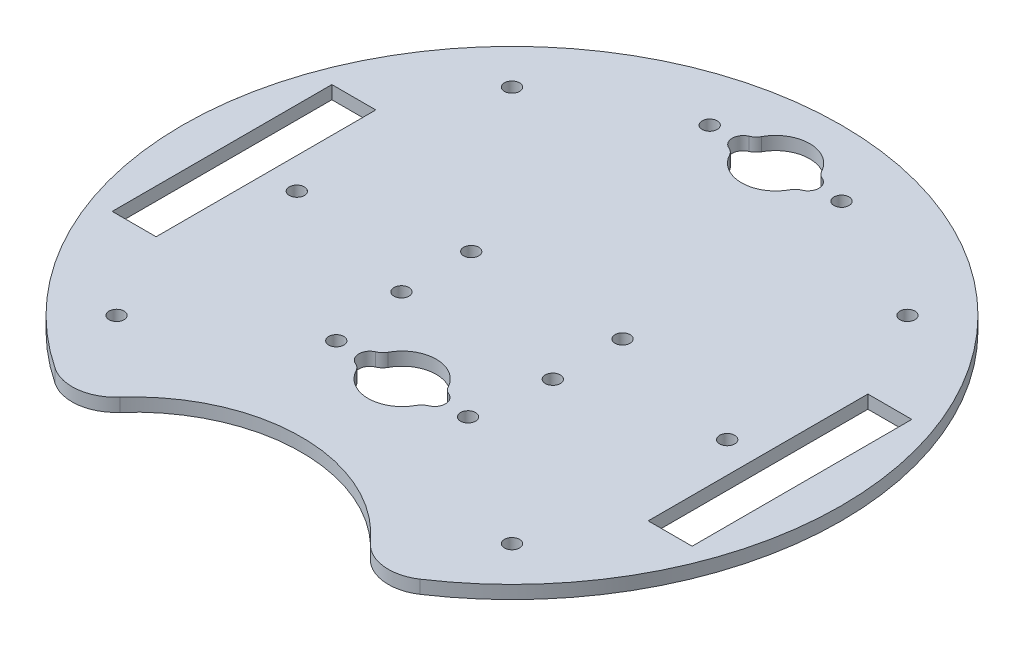
from build123d import *

# Parameters (mm, degrees)
SKETCH1_R           = 75
BOSS_EXTRUDE1_DEPTH = 3
SKETCH2_W           = 10
SKETCH2_H           = 50
CUT_EXTRUDE1_DEPTH  = 6.35
CUT_EXTRUDE2_DEPTH  = 10
CUT_EXTRUDE3_START  = -10
CUT_EXTRUDE3_DEPTH  = 10
FILLET2_R           = 10
SKETCH7_R           = 1.7145
CUT_EXTRUDE5_DEPTH  = 3
SKETCH6_R           = 1.7145
CUT_EXTRUDE6_DEPTH  = 3
FILLET4_R           = 3
SKETCH8_R           = 1.7145
CUT_EXTRUDE7_DEPTH  = 107.108435247


with BuildPart() as part:
    # Sketch1 → Boss-Extrude1 (new body)
    with BuildSketch(Plane(origin=(0, 0, 0), x_dir=(1, 0, 0), z_dir=(0, 1, 0))):
        Circle(SKETCH1_R)
    extrude(amount=BOSS_EXTRUDE1_DEPTH)

    # Sketch2 → Cut-Extrude1 (cut)
    with BuildSketch(Plane(origin=(0, 3, 0), x_dir=(1, 0, 0), z_dir=(0, 1, 0))):
        with Locations((-61, 0)):
            Rectangle(SKETCH2_W, SKETCH2_H)
        with Locations((61, 0)):
            Rectangle(SKETCH2_W, SKETCH2_H)
    extrude(amount=-CUT_EXTRUDE1_DEPTH, mode=Mode.SUBTRACT)

    # Sketch3 → Cut-Extrude2 (cut)
    with BuildSketch(Plane(origin=(0, 3, 0), x_dir=(1, 0, 0), z_dir=(0, 1, 0))):
        with BuildLine():
            ThreePointArc((-7.335762693, -27.499817134), (0, -32.75), (7.335762693, -27.499817134))
            ThreePointArc((7.335762693, -27.499817134), (9.866, -25), (7.335762693, -22.500182866))
            ThreePointArc((7.335762693, -22.500182866), (0, -17.25), (-7.335762693, -22.500182866))
            ThreePointArc((-7.335762693, -22.500182866), (-9.866, -25), (-7.335762693, -27.499817134))
        make_face()
        with BuildLine():
            ThreePointArc((-7.335762693, 62.499817134), (-9.866, 60), (-7.335762693, 57.500182866))
            ThreePointArc((-7.335762693, 57.500182866), (0, 52.25), (7.335762693, 57.500182866))
            ThreePointArc((7.335762693, 57.500182866), (9.866, 60), (7.335762693, 62.499817134))
            ThreePointArc((7.335762693, 62.499817134), (0, 67.75), (-7.335762693, 62.499817134))
        make_face()
    extrude(amount=-CUT_EXTRUDE2_DEPTH, mode=Mode.SUBTRACT)

    # Sketch4 → Cut-Extrude3 (cut)
    with BuildSketch(Plane(origin=(0, 3, 0), x_dir=(1, 0, 0), z_dir=(0, 1, 0)).offset(CUT_EXTRUDE3_START)):
        with BuildLine():
            ThreePointArc((-33.160552015, -67.270928268), (0, -47.932265908), (33.160552015, -67.270928268))
            ThreePointArc((33.160552015, -67.270928268), (0, -75), (-33.160552015, -67.270928268))
        make_face()
    extrude(amount=CUT_EXTRUDE3_DEPTH, mode=Mode.SUBTRACT)

    # Fillet2
    fillet2_edges = [part.edges().sort_by_distance(p)[0] for p in [
        (33.160552015, 1.5, 67.270928268),
        (-33.160552015, 1.5, 67.270928268),
    ]]
    fillet(fillet2_edges, radius=FILLET2_R)

    # Sketch7 → Cut-Extrude5 (cut)
    with BuildSketch(Plane(origin=(0, 3, 0), x_dir=(1, 0, 0), z_dir=(0, 1, 0))):
        with Locations((-48.975, 0)):
            Circle(SKETCH7_R)
        with Locations((-17.225, -7.9375)):
            Circle(SKETCH7_R)
        with Locations((-17.225, 7.9375)):
            Circle(SKETCH7_R)
        with Locations((17.225, 7.9375)):
            Circle(SKETCH7_R)
        with Locations((17.225, -7.9375)):
            Circle(SKETCH7_R)
        with Locations((48.975, 0)):
            Circle(SKETCH7_R)
    extrude(amount=-CUT_EXTRUDE5_DEPTH, mode=Mode.SUBTRACT)

    # Sketch6 → Cut-Extrude6 (cut)
    with BuildSketch(Plane(origin=(0, 3, 0), x_dir=(1, 0, 0), z_dir=(0, 1, 0))):
        with Locations((-15, 60)):
            Circle(SKETCH6_R)
        with Locations((15, 60)):
            Circle(SKETCH6_R)
        with Locations((-15, -25)):
            Circle(SKETCH6_R)
        with Locations((15, -25)):
            Circle(SKETCH6_R)
    extrude(amount=-CUT_EXTRUDE6_DEPTH, mode=Mode.SUBTRACT)

    # Fillet4
    fillet4_edges = [part.edges().sort_by_distance(p)[0] for p in [
        (-7.335762693, 1.5, -57.500182866),
        (7.335762693, 1.5, -57.500182866),
        (7.335762693, 1.5, -62.499817134),
        (-7.335762693, 1.5, -62.499817134),
        (7.335762693, 1.5, 22.500182866),
        (-7.335762693, 1.5, 22.500182866),
        (7.335762693, 1.5, 27.499817134),
        (-7.335762693, 1.5, 27.499817134),
    ]]
    fillet(fillet4_edges, radius=FILLET4_R)

    # Sketch8 → Cut-Extrude7 (cut, through all)
    with BuildSketch(Plane(origin=(0, 3, 0), x_dir=(1, 0, 0), z_dir=(0, 1, 0))):
        with Locations((-45, 45)):
            Circle(SKETCH8_R)
        with Locations((45, 45)):
            Circle(SKETCH8_R)
        with Locations((45, -45)):
            Circle(SKETCH8_R)
        with Locations((-45, -45)):
            Circle(SKETCH8_R)
    extrude(amount=-CUT_EXTRUDE7_DEPTH, mode=Mode.SUBTRACT)


solid = part.part
